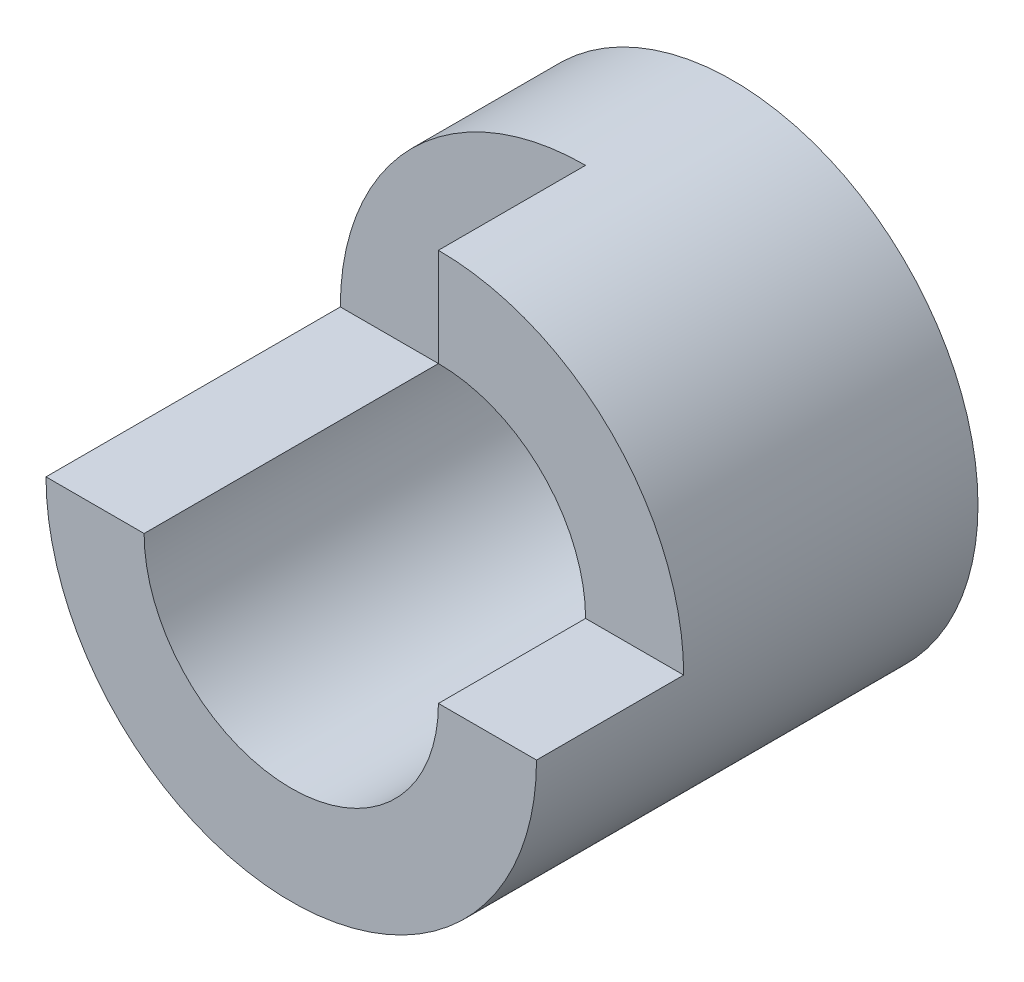
from build123d import *

# Parameters (mm, degrees)
SKETCH1_R           = 5
SKETCH1_R_2         = 3
BOSS_EXTRUDE1_DEPTH = 9
CUT_EXTRUDE1_DEPTH  = 9


with BuildPart() as part:
    # Sketch1 → Boss-Extrude1 (new body)
    with BuildSketch(Plane.XY):
        Circle(SKETCH1_R)
        Circle(SKETCH1_R_2, mode=Mode.SUBTRACT)
    extrude(amount=BOSS_EXTRUDE1_DEPTH)

    # Sketch2 → Cut-Extrude1 (cut)
    with BuildSketch(Plane(origin=(0, 0, 0), x_dir=(1, 0, 0), z_dir=(0, 1, 0))):
        Polygon((-5, -3), (0, -3), (0, -6), (3.187015058, -6), (6.391445499, -6), (6.391445499, -9.698491775), (-6.043137843, -9.698491775), (-6.043137843, -2.314369455), (-5, -2.436277134), align=None)
    extrude(amount=CUT_EXTRUDE1_DEPTH, mode=Mode.SUBTRACT)


solid = part.part
